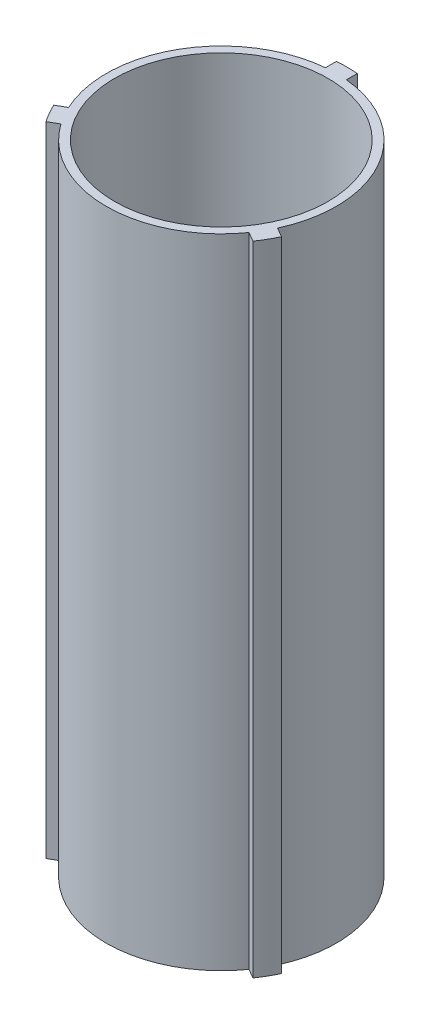
from build123d import *

# Parameters (mm, degrees)
SKETCH1_R           = 32.385
BOSS_EXTRUDE1_DEPTH = 193.675


with BuildPart() as part:
    # Sketch1 → Boss-Extrude1 (new body)
    with BuildSketch(Plane(origin=(0, 0, 0), x_dir=(1, 0, 0), z_dir=(0, 1, 0))):
        with BuildLine():
            Line((-3.175, 34.780382402), (-3.175, 38.094919661))
            ThreePointArc((-3.175, 38.094919661), (0, 38.227), (3.175, 38.094919661))
            Line((3.175, 38.094919661), (3.175, 34.780382402))
            ThreePointArc((3.175, 34.780382402), (30.245937227, 17.4625), (31.708194713, -14.640560544))
            Line((31.708194713, -14.640560544), (34.578668182, -16.297829174))
            ThreePointArc((34.578668182, -16.297829174), (33.10555311, -19.1135), (31.403668182, -21.797090488))
            Line((31.403668182, -21.797090488), (28.533194713, -20.139821858))
            ThreePointArc((28.533194713, -20.139821858), (0, -34.925), (-28.533194713, -20.139821858))
            Line((-28.533194713, -20.139821858), (-31.403668182, -21.797090488))
            ThreePointArc((-31.403668182, -21.797090488), (-33.10555311, -19.1135), (-34.578668182, -16.297829174))
            Line((-34.578668182, -16.297829174), (-31.708194713, -14.640560544))
            ThreePointArc((-31.708194713, -14.640560544), (-30.245937227, 17.4625), (-3.175, 34.780382402))
        make_face()
        Circle(SKETCH1_R, mode=Mode.SUBTRACT)
    extrude(amount=BOSS_EXTRUDE1_DEPTH)


solid = part.part
